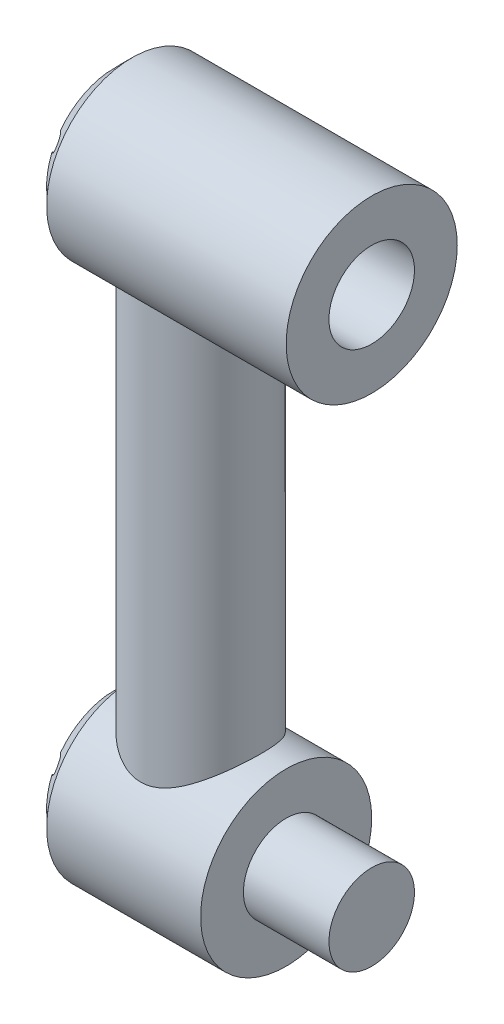
from build123d import *

# Parameters (mm, degrees)
SKETCH1_R           = 88.9
BOSS_EXTRUDE1_DEPTH = 317.5
SKETCH4_R           = 127
BOSS_EXTRUDE2_DEPTH = 127
SKETCH5_R           = 63.5
BOSS_EXTRUDE3_DEPTH = 127
SKETCH6_R           = 127
SKETCH6_R_2         = 63.5
BOSS_EXTRUDE4_DEPTH = 127
CHAMFER1_SIZE       = 25.4
SKETCH7_R           = 12.7
CUT_EXTRUDE1_DEPTH  = 25.4


with BuildPart() as part:
    # Sketch1 → Boss-Extrude1 (new body, symmetric)
    with BuildSketch(Plane(origin=(0, 0, 0), x_dir=(1, 0, 0), z_dir=(0, 1, 0))):
        Circle(SKETCH1_R)
    extrude(amount=BOSS_EXTRUDE1_DEPTH, both=True)

    # Sketch4 → Boss-Extrude2 (add, symmetric)
    with BuildSketch(Plane(origin=(0, 0, 0), x_dir=(0, 0, -1), z_dir=(1, 0, 0))):
        with Locations((0, 406.4)):
            Circle(SKETCH4_R)
        with Locations((0, -393.7)):
            Circle(SKETCH4_R)
    extrude(amount=BOSS_EXTRUDE2_DEPTH, both=True)

    # Sketch5 → Boss-Extrude3 (add)
    with BuildSketch(Plane(origin=(127, 0, 0), x_dir=(0, 0, -1), z_dir=(1, 0, 0))):
        with Locations((0, -393.7)):
            Circle(SKETCH5_R)
    extrude(amount=BOSS_EXTRUDE3_DEPTH)

    # Sketch6 → Boss-Extrude4 (add)
    with BuildSketch(Plane(origin=(127, 0, 0), x_dir=(0, 0, -1), z_dir=(1, 0, 0))):
        with Locations((0, 406.4)):
            Circle(SKETCH6_R)
        with Locations((0, 406.4)):
            Circle(SKETCH6_R_2, mode=Mode.SUBTRACT)
    extrude(amount=BOSS_EXTRUDE4_DEPTH)

    # Chamfer1
    chamfer1_edges = [part.edges().sort_by_distance(p)[0] for p in [
        (-127, -393.7, 127),
        (-127, 406.4, 127),
    ]]
    chamfer(chamfer1_edges, length=CHAMFER1_SIZE)

    # Sketch7 → Cut-Extrude1 (cut)
    with BuildSketch(Plane.ZY.offset(127)):
        with Locations((0, 508)):
            Circle(SKETCH7_R)
        with Locations((87.988181025, 457.2)):
            Circle(SKETCH7_R)
        with Locations((87.988181025, 355.6)):
            Circle(SKETCH7_R)
        with Locations((0, 304.8)):
            Circle(SKETCH7_R)
        with Locations((-87.988181024, 355.6)):
            Circle(SKETCH7_R)
        with Locations((-87.988181024, 457.2)):
            Circle(SKETCH7_R)
        with Locations((0, -292.1)):
            Circle(SKETCH7_R)
        with Locations((87.988181025, -342.9)):
            Circle(SKETCH7_R)
        with Locations((87.988181025, -444.5)):
            Circle(SKETCH7_R)
        with Locations((0, -495.3)):
            Circle(SKETCH7_R)
        with Locations((-87.988181024, -444.5)):
            Circle(SKETCH7_R)
        with Locations((-87.988181024, -342.9)):
            Circle(SKETCH7_R)
    extrude(amount=-CUT_EXTRUDE1_DEPTH, mode=Mode.SUBTRACT)


solid = part.part
